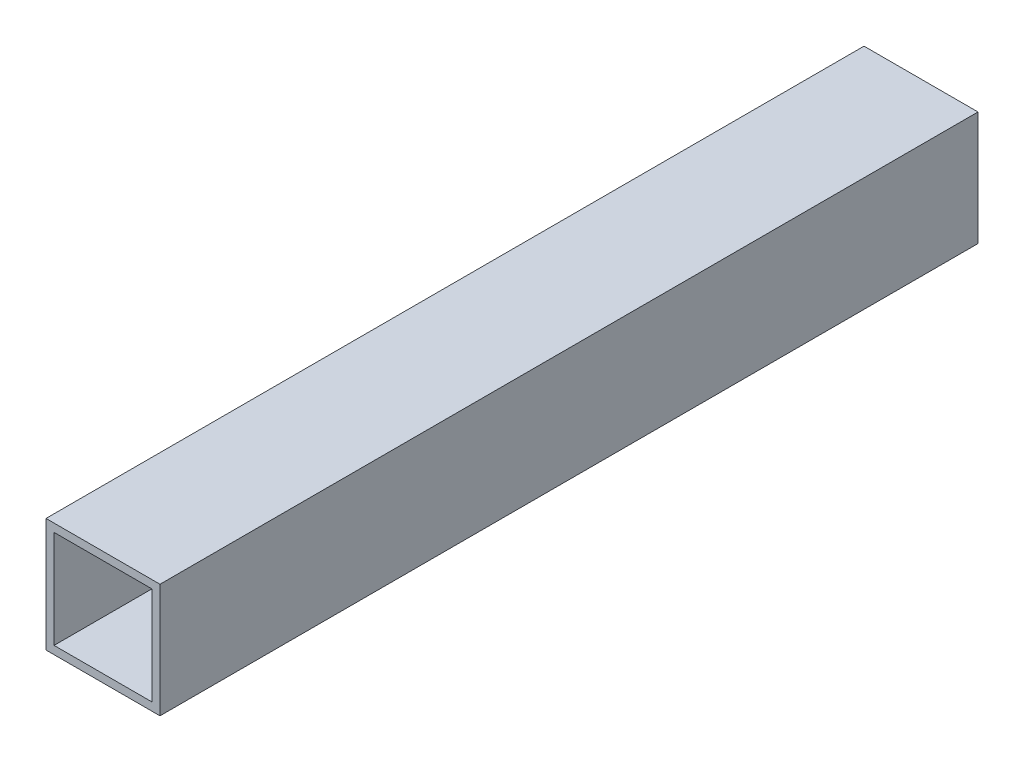
from build123d import *

# Parameters (mm, degrees)
SKETCH1_W           = 17
SKETCH1_H           = 17
SKETCH1_W_2         = 14.6
SKETCH1_H_2         = 14.6
BOSS_EXTRUDE1_DEPTH = 122


with BuildPart() as part:
    # Sketch1 → Boss-Extrude1 (new body)
    with BuildSketch(Plane.XY):
        Rectangle(SKETCH1_W, SKETCH1_H)
        Rectangle(SKETCH1_W_2, SKETCH1_H_2, mode=Mode.SUBTRACT)
    extrude(amount=BOSS_EXTRUDE1_DEPTH)


solid = part.part
